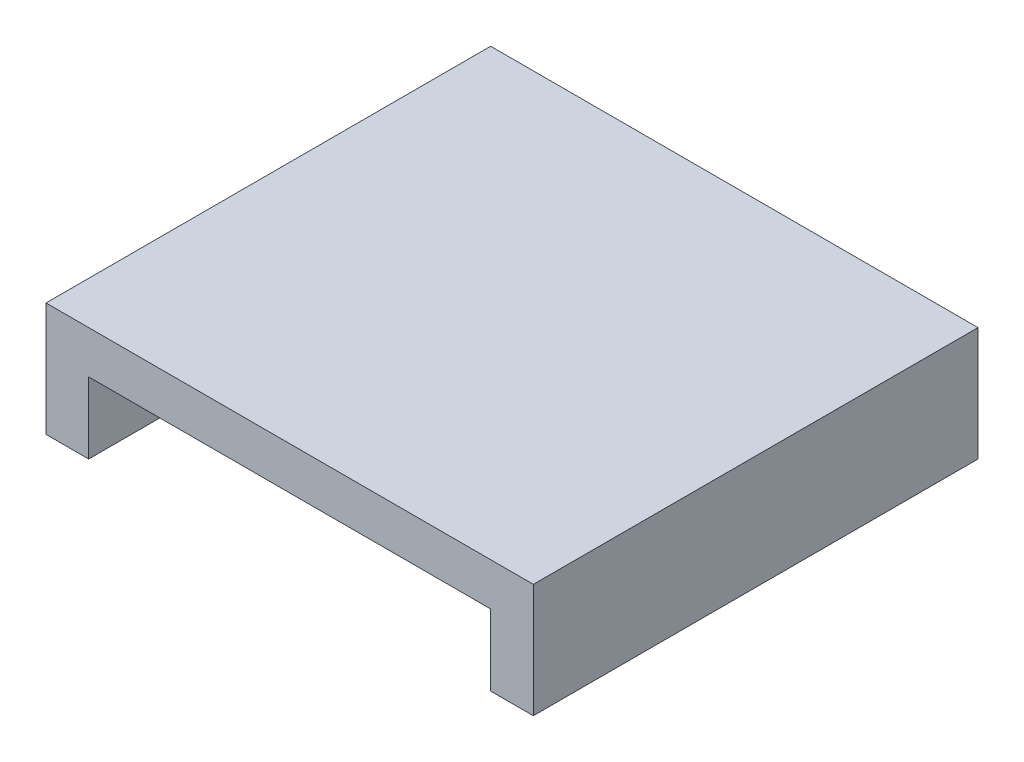
from build123d import *

# Parameters (mm, degrees)
SKETCH1_W           = 56.5
SKETCH1_H           = 56.5
BOSS_EXTRUDE1_DEPTH = 10
SHELL1_T            = 6


with BuildPart() as part:
    # Sketch1 → Boss-Extrude1 (new body)
    with BuildSketch(Plane(origin=(0, 0, 0), x_dir=(1, 0, 0), z_dir=(0, 1, 0))):
        Rectangle(SKETCH1_W, SKETCH1_H)
    extrude(amount=BOSS_EXTRUDE1_DEPTH)

    # Shell1
    shell1_openings = [part.faces().sort_by_distance(p)[0] for p in [
        (0, 5, 28.25),
        (0, 0, 0),
    ]]
    offset(amount=SHELL1_T, openings=shell1_openings, kind=Kind.INTERSECTION)


solid = part.part
